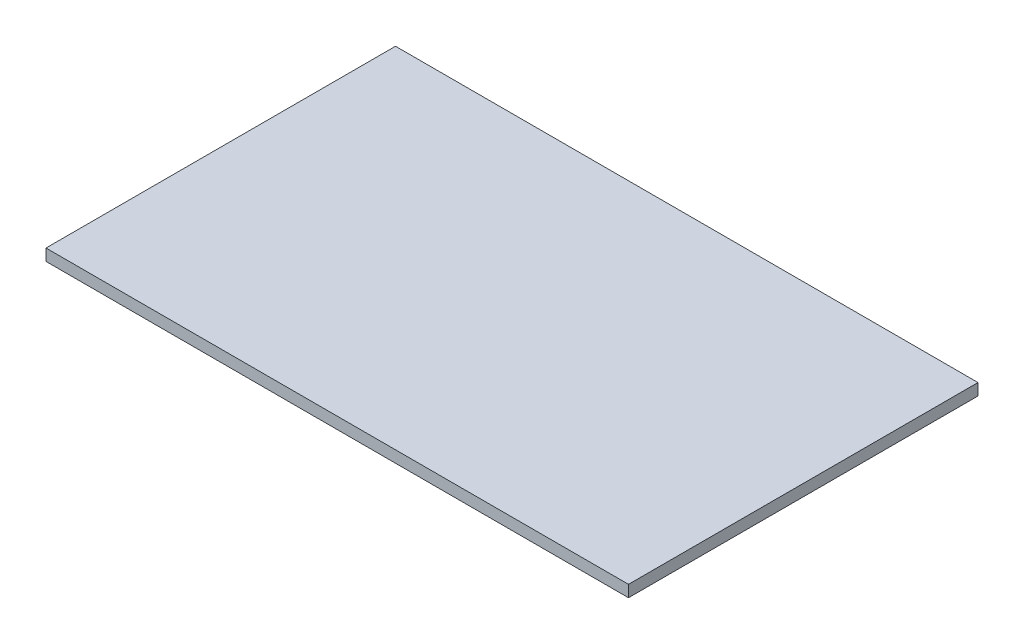
from build123d import *

# Parameters (mm, degrees)
SKETCH1_W           = 250
SKETCH1_H           = 150
BOSS_EXTRUDE1_DEPTH = 5


with BuildPart() as part:
    # Sketch1 → Boss-Extrude1 (new body)
    with BuildSketch(Plane(origin=(0, 0, 0), x_dir=(1, 0, 0), z_dir=(0, 1, 0))):
        with Locations((125, 75)):
            Rectangle(SKETCH1_W, SKETCH1_H)
    extrude(amount=BOSS_EXTRUDE1_DEPTH)


solid = part.part
